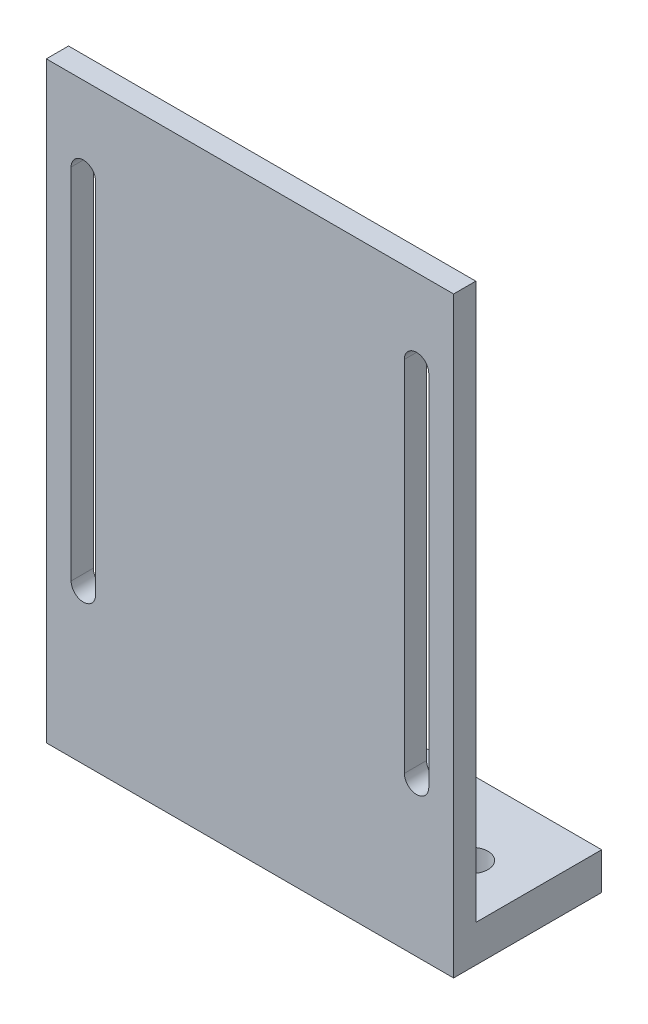
from build123d import *

# Parameters (mm, degrees)
SKETCH1_W           = 55
SKETCH1_H           = 20
SKETCH1_R           = 2.15
BOSS_EXTRUDE1_DEPTH = 5
SKETCH2_W           = 55
SKETCH2_H           = 3
BOSS_EXTRUDE2_DEPTH = 75
CUT_EXTRUDE1_DEPTH  = 75


with BuildPart() as part:
    # Sketch1 → Boss-Extrude1 (new body)
    with BuildSketch(Plane(origin=(0, 0, 0), x_dir=(1, 0, 0), z_dir=(0, 1, 0))):
        Rectangle(SKETCH1_W, SKETCH1_H)
        with Locations((-20, 0)):
            Circle(SKETCH1_R, mode=Mode.SUBTRACT)
        with Locations((20, 0)):
            Circle(SKETCH1_R, mode=Mode.SUBTRACT)
    extrude(amount=BOSS_EXTRUDE1_DEPTH)

    # Sketch2 → Boss-Extrude2 (add)
    with BuildSketch(Plane(origin=(0, 5, 0), x_dir=(1, 0, 0), z_dir=(0, 1, 0))):
        with Locations((0, -8.5)):
            Rectangle(SKETCH2_W, SKETCH2_H)
    extrude(amount=BOSS_EXTRUDE2_DEPTH)

    # Sketch3 → Cut-Extrude1 (cut)
    with BuildSketch(Plane(origin=(0, 0, 7), x_dir=(-1, 0, 0), z_dir=(0, 0, -1))):
        with BuildLine():
            Line((-20.85, 69.022285576), (-20.85, 20.608862032))
            ThreePointArc((-20.85, 20.608862032), (-22.5, 18.958862032), (-24.15, 20.608862032))
            Line((-24.15, 20.608862032), (-24.15, 69.022285576))
            ThreePointArc((-24.15, 69.022285576), (-22.5, 70.672285576), (-20.85, 69.022285576))
        make_face()
        with BuildLine():
            Line((20.85, 69.022285576), (20.85, 20.608862032))
            ThreePointArc((20.85, 20.608862032), (22.5, 18.958862032), (24.15, 20.608862032))
            Line((24.15, 20.608862032), (24.15, 69.022285576))
            ThreePointArc((24.15, 69.022285576), (22.5, 70.672285576), (20.85, 69.022285576))
        make_face()
    extrude(amount=-CUT_EXTRUDE1_DEPTH, mode=Mode.SUBTRACT)


solid = part.part
